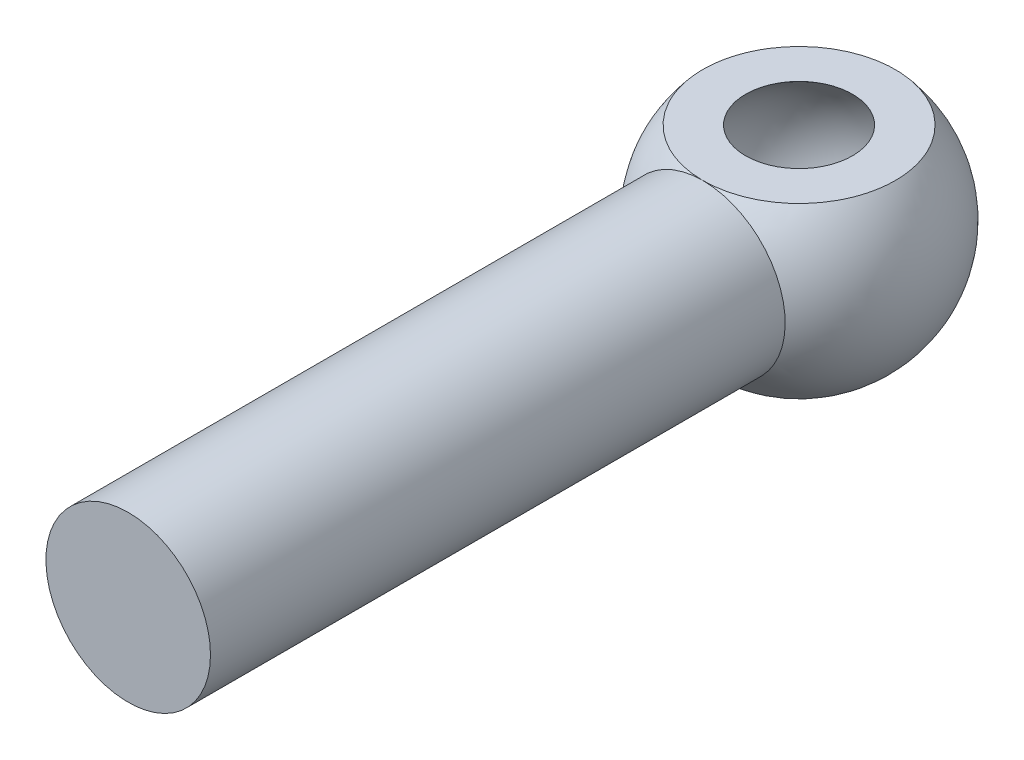
from build123d import *

# Parameters (mm, degrees)
SKETCH1_R      = 1.651
EXTRUDE1_DEPTH = 13.462
SKETCH6_R      = 2.782872309
EXTRUDE2_DEPTH = 1.889


with BuildPart() as part:
    # Sketch1 → Extrude1 (new body)
    with BuildSketch(Plane.XY):
        Circle(SKETCH1_R)
    extrude(amount=EXTRUDE1_DEPTH)

    # Sketch2 → Revolve1 (revolve)
    with BuildSketch(Plane(origin=(0, 0, 0), x_dir=(-1, 0, 0), z_dir=(0, 0, -1))):
        with BuildLine():
            Line((2.54, 0), (-2.54, 0))
            ThreePointArc((-2.54, 0), (0, 2.54), (2.54, 0))
        make_face()
    revolve(axis=Axis((-2.54, 0, 0), (1, 0, 0)))

    # Sketch6 → Extrude2 (cut, through all)
    with BuildSketch(Plane(origin=(0, 1.651, 0), x_dir=(-1, 0, 0), z_dir=(0, 1, 0))):
        Circle(SKETCH6_R)
    extrude(amount=EXTRUDE2_DEPTH, mode=Mode.SUBTRACT)

    # Sketch7 → Cut-Revolve1 (revolve, cut)
    with BuildSketch(Plane(origin=(0, 0, 0), x_dir=(-1, 0, 0), z_dir=(0, 1, 0))):
        with BuildLine():
            Line((0, 1.9685), (0, -1.9685))
            ThreePointArc((0, -1.9685), (1.9685, 0), (0, 1.9685))
        make_face()
    revolve(axis=Axis((0, 0, 1.9685), (0, 0, -1)), mode=Mode.SUBTRACT)


solid = part.part
